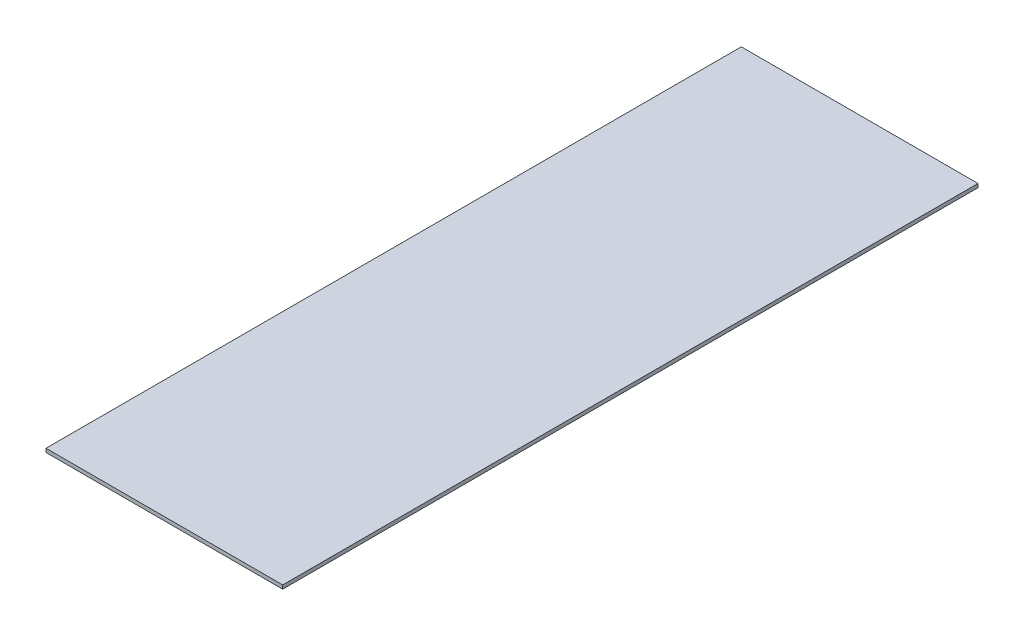
from build123d import *

# Parameters (mm, degrees)
SKETCH2_W           = 50.8
SKETCH2_H           = 149.225
BOSS_EXTRUDE1_DEPTH = 0.79375


with BuildPart() as part:
    # Sketch2 → Boss-Extrude1 (new body)
    with BuildSketch(Plane(origin=(0, 0, 0), x_dir=(1, 0, 0), z_dir=(0, 1, 0))):
        Rectangle(SKETCH2_W, SKETCH2_H)
    extrude(amount=BOSS_EXTRUDE1_DEPTH)


solid = part.part
